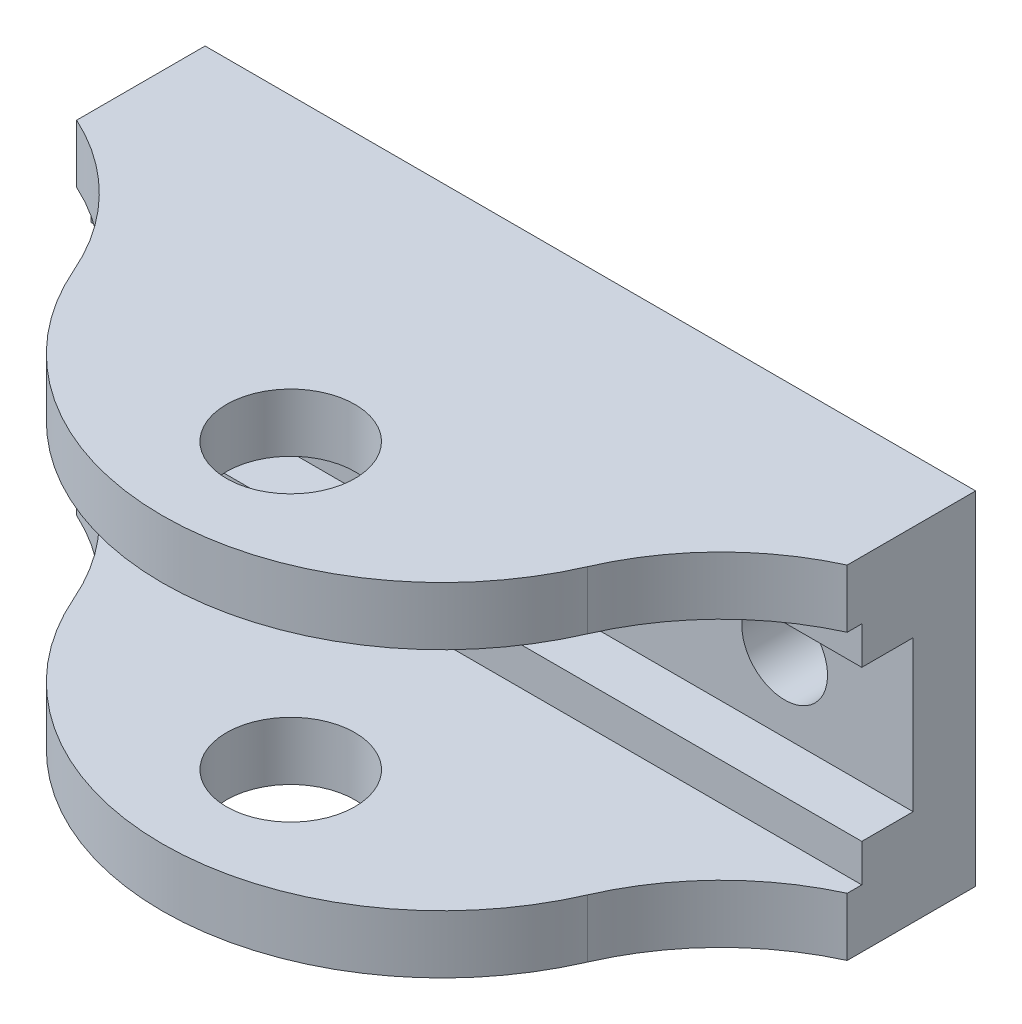
from build123d import *

# Parameters (mm, degrees)
SKETCH2_R      = 3.175
EXTRUDE1_DEPTH = 38.1
SKETCH3_W      = 57.15
SKETCH3_H      = 11.176
EXTRUDE2_DEPTH = 33.4645
SKETCH4_W      = 57.15
SKETCH4_H      = 16.764
EXTRUDE3_DEPTH = 29.6545
SKETCH5_R      = 4.7625
EXTRUDE4_DEPTH = 26.4
EXTRUDE5_DEPTH = 26.4


with BuildPart() as part:
    # Sketch2 → Extrude1 (new body)
    with BuildSketch(Plane.XY):
        Polygon((-22.225, 12.7), (-28.575, 12.7), (-28.575, -12.7), (-22.225, -12.7), (22.225, -12.7), (28.575, -12.7), (28.575, 12.7), (22.225, 12.7), align=None)
        with Locations((19.05, 0)):
            Circle(SKETCH2_R, mode=Mode.SUBTRACT)
        with Locations((-19.05, 0)):
            Circle(SKETCH2_R, mode=Mode.SUBTRACT)
    extrude(amount=EXTRUDE1_DEPTH)

    # Sketch3 → Extrude2 (cut)
    with BuildSketch(Plane.XY.offset(38.1)):
        Rectangle(SKETCH3_W, SKETCH3_H)
    extrude(amount=-EXTRUDE2_DEPTH, mode=Mode.SUBTRACT)

    # Sketch4 → Extrude3 (cut)
    with BuildSketch(Plane.XY.offset(38.1)):
        Rectangle(SKETCH4_W, SKETCH4_H)
    extrude(amount=-EXTRUDE3_DEPTH, mode=Mode.SUBTRACT)

    # Sketch5 → Extrude4 (cut, through all)
    with BuildSketch(Plane(origin=(0, 12.7, 0), x_dir=(-1, 0, 0), z_dir=(0, 1, 0))):
        with Locations((0, 22.225)):
            Circle(SKETCH5_R)
    extrude(amount=-EXTRUDE4_DEPTH, mode=Mode.SUBTRACT)

    # Sketch6 → Extrude5 (cut, through all)
    with BuildSketch(Plane(origin=(0, 12.7, 0), x_dir=(1, 0, 0), z_dir=(0, 1, 0))):
        with BuildLine():
            Line((-28.575, -9.525), (-28.575, -38.1))
            Line((-28.575, -38.1), (28.575, -38.1))
            Line((28.575, -38.1), (28.575, -9.525))
            ThreePointArc((28.575, -9.525), (22.913958086, -13.508463236), (19.05, -19.25173781))
            ThreePointArc((19.05, -19.25173781), (0, -31.75), (-19.05, -19.25173781))
            ThreePointArc((-19.05, -19.25173781), (-22.913958086, -13.508463236), (-28.575, -9.525))
        make_face()
    extrude(amount=-EXTRUDE5_DEPTH, mode=Mode.SUBTRACT)


solid = part.part
